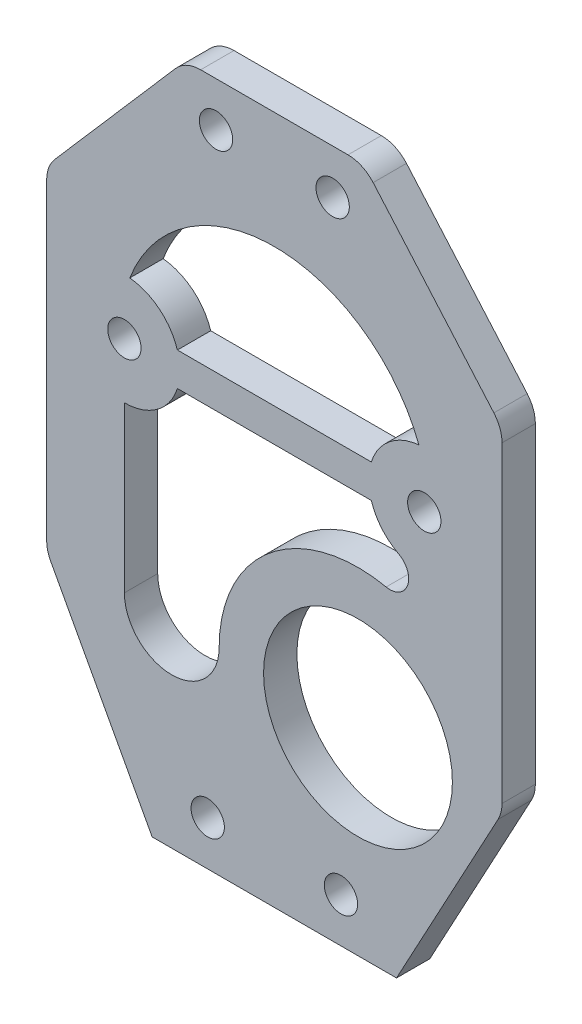
from build123d import *

# Parameters (mm, degrees)
SKETCH1_R           = 1.5
SKETCH1_R_2         = 8.5
BOSS_EXTRUDE1_DEPTH = 1.5
FILLET1_R           = 3


with BuildPart() as part:
    # Sketch1 → Boss-Extrude1 (new body, symmetric)
    with BuildSketch(Plane.XY):
        Polygon((8, 24.400284093), (-8, 24.400284093), (-20.5, 10), (-20.5, -20), (-11, -37.599715907), (11, -37.599715907), (20.5, -20), (20.5, 10), align=None)
        with Locations((-5.25, 20.39454584)):
            Circle(SKETCH1_R, mode=Mode.SUBTRACT)
        with Locations((-13.5, 0)):
            Circle(SKETCH1_R, mode=Mode.SUBTRACT)
        with Locations((-6, -33.599715907)):
            Circle(SKETCH1_R, mode=Mode.SUBTRACT)
        with Locations((6, -33.599715907)):
            Circle(SKETCH1_R, mode=Mode.SUBTRACT)
        with Locations((13.5, 0)):
            Circle(SKETCH1_R, mode=Mode.SUBTRACT)
        with Locations((5.25, 20.39454584)):
            Circle(SKETCH1_R, mode=Mode.SUBTRACT)
        with Locations((7.530163354, -19.817414772)):
            Circle(SKETCH1_R_2, mode=Mode.SUBTRACT)
        with BuildLine():
            Line((-13.5, -5), (-13.5, -19.817414772))
            ThreePointArc((-13.5, -19.817414772), (-9.234918323, -24.082496449), (-4.969836646, -19.817414772))
            ThreePointArc((-4.969836646, -19.817414772), (-0.361028795, -10.12313365), (10.06681719, -7.57750516))
            ThreePointArc((10.06681719, -7.57750516), (11.99598649, -6.493442694), (11.187975781, -4.433344563))
            ThreePointArc((11.187975781, -4.433344563), (9.667400631, -3.211102938), (8.730303993, -1.5))
            Line((8.730303993, -1.5), (-8.730303993, -1.5))
            ThreePointArc((-8.730303993, -1.5), (-10.541960108, -4.031128874), (-13.5, -5))
        make_face(mode=Mode.SUBTRACT)
        with BuildLine():
            Line((-8.730303993, 1.5), (8.730303993, 1.5))
            ThreePointArc((8.730303993, 1.5), (10.349605217, 3.882655368), (13.014734561, 4.976396031))
            ThreePointArc((13.014734561, 4.976396031), (0, 13.933694167), (-13.014734561, 4.976396031))
            ThreePointArc((-13.014734561, 4.976396031), (-10.349605217, 3.882655368), (-8.730303993, 1.5))
        make_face(mode=Mode.SUBTRACT)
    extrude(amount=BOSS_EXTRUDE1_DEPTH, both=True)

    # Fillet1
    fillet1_edges = [part.edges().sort_by_distance(p)[0] for p in [
        (-20.5, -20, 0),
        (-20.5, 10, 0),
        (-8, 24.400284093, 0),
        (8, 24.400284093, 0),
        (20.5, 10, 0),
        (20.5, -20, 0),
    ]]
    fillet(fillet1_edges, radius=FILLET1_R)


solid = part.part
